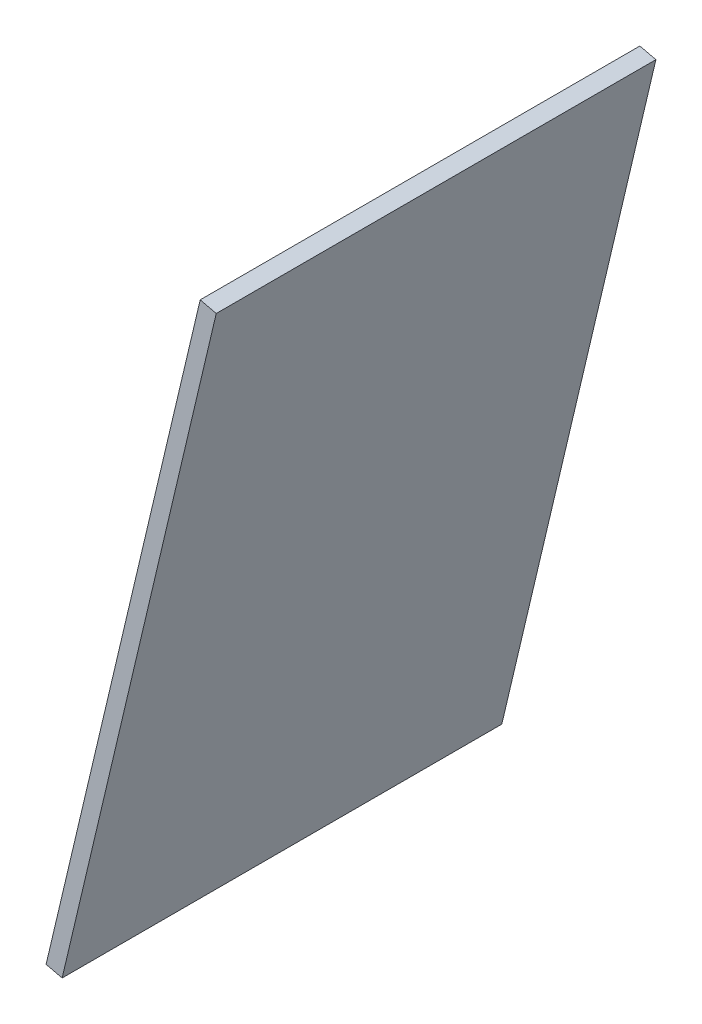
from build123d import *

# Parameters (mm, degrees)
SKETCH2_W           = 122
SKETCH2_H           = 80
BOSS_EXTRUDE1_DEPTH = 3


with BuildPart() as part:
    # Sketch2 → Boss-Extrude1 (new body)
    with BuildSketch(Plane(origin=(-379.283039191, -1272.36355708, 6580.764619776), x_dir=(0.229832584, 0.97323018, 0), z_dir=(-0.97323018, 0.229832584, 0))):
        with Locations((195.06174199, 418.694483006)):
            Rectangle(SKETCH2_W, SKETCH2_H)
    extrude(amount=BOSS_EXTRUDE1_DEPTH)


solid = part.part
